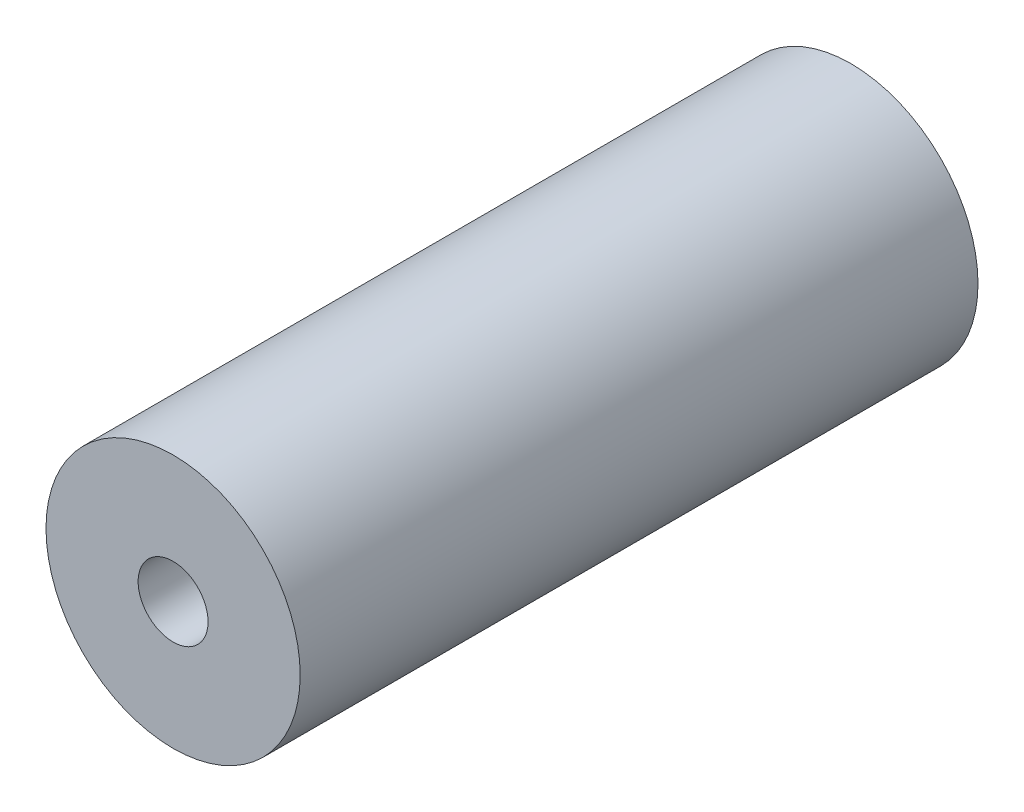
from build123d import *

# Parameters (mm, degrees)
ESQUISSE1_R        = 6
BOSS_EXTRU_1_DEPTH = 16


with BuildPart() as part:
    # Esquisse1 → Boss.-Extru.1 (new body, symmetric)
    with BuildSketch(Plane.XY):
        Circle(ESQUISSE1_R)
    extrude(amount=BOSS_EXTRU_1_DEPTH, both=True)

    # Esquisse4 → Trou taraudé M41 (revolve, cut)
    with BuildSketch(Plane(origin=(0, 0, 16), x_dir=(0, -1, 0), z_dir=(1, 0, 0))):
        Polygon((0, 0), (0, 12.491420021), (1.65, 11.5), (1.65, 0), align=None)
    trou_taraud_m41 = revolve(axis=Axis((0, 0, 22.35), (0, 0, -1)), mode=Mode.SUBTRACT)

    # Symétrie1: Trou taraudé M41 across plane
    add(trou_taraud_m41.mirror(Plane.XY), mode=Mode.SUBTRACT)


solid = part.part
